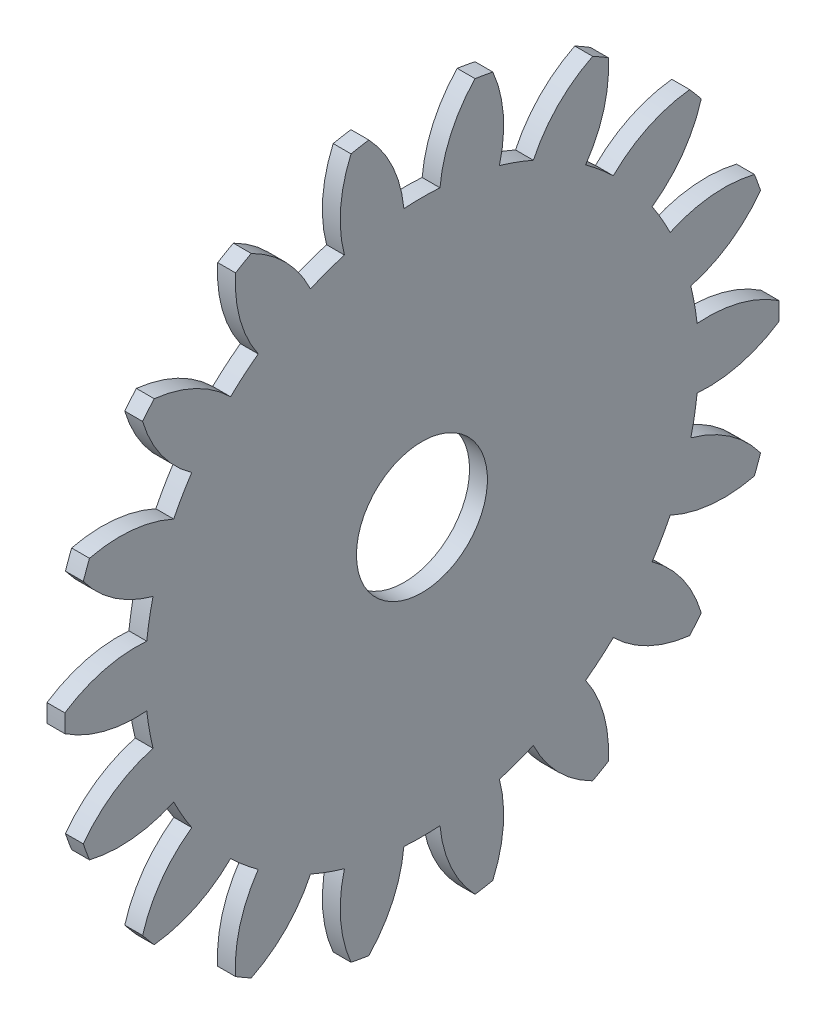
from build123d import *

# Parameters (mm, degrees)
BASPROSKE_W     = 3
BASPROSKE_H     = 60
TOOTHCUT_DEPTH  = 85.905830188
TEETHCUTS_COUNT = 18
TEETHCUTS_ANGLE = 340
BORSKE_R        = 11
BORE_DEPTH      = 50.0000508


with BuildPart() as part:
    # BasProSke → Base-Revolve (revolve)
    with BuildSketch(Plane(origin=(0, 0, 0), x_dir=(1, 0, 0), z_dir=(0, 1, 0)), mode=Mode.PRIVATE) as base_revolve_sk:
        with Locations((1.5, 30)):
            Rectangle(BASPROSKE_W, BASPROSKE_H)
    revolve(base_revolve_sk.sketch.rotate(Axis((-10, 0, 0), (1, 0, 0)), 180), axis=Axis((-10, 0, 0), (1, 0, 0)))

    # TooCutSke → ToothCut (cut, through all)
    with BuildSketch(Plane(origin=(0, 0, 0), x_dir=(0, 0, -1), z_dir=(1, 0, 0))):
        with BuildLine():
            ThreePointArc((3.032632993, 46.400001488), (0, 46.499), (-3.032632993, 46.400001488))
            ThreePointArc((-3.032632993, 46.400001488), (-4.88926752, 53.378783166), (-8.942523553, 59.355538222))
            ThreePointArc((-8.942523553, 59.355538222), (0, 60.0254), (8.942523553, 59.355538222))
            ThreePointArc((8.942523553, 59.355538222), (4.88926752, 53.378783166), (3.032632993, 46.400001488))
        make_face()
    toothcut = extrude(amount=TOOTHCUT_DEPTH, mode=Mode.SUBTRACT)

    # TeethCuts: ToothCut ×18 about axis
    teethcuts_axis = Axis((-10, 0, 0), (1, 0, 0))
    for i in range(1, TEETHCUTS_COUNT):
        add(toothcut.rotate(teethcuts_axis, i * TEETHCUTS_ANGLE / (TEETHCUTS_COUNT - 1)), mode=Mode.SUBTRACT)

    # BorSke → Bore (cut, symmetric)
    with BuildSketch(Plane(origin=(0, 0, 0), x_dir=(0, 0, -1), z_dir=(1, 0, 0))):
        with Locations(Location((0, 0, 0), (0, 0, 180))):
            Circle(BORSKE_R)
    extrude(amount=BORE_DEPTH, both=True, mode=Mode.SUBTRACT)


solid = part.part
